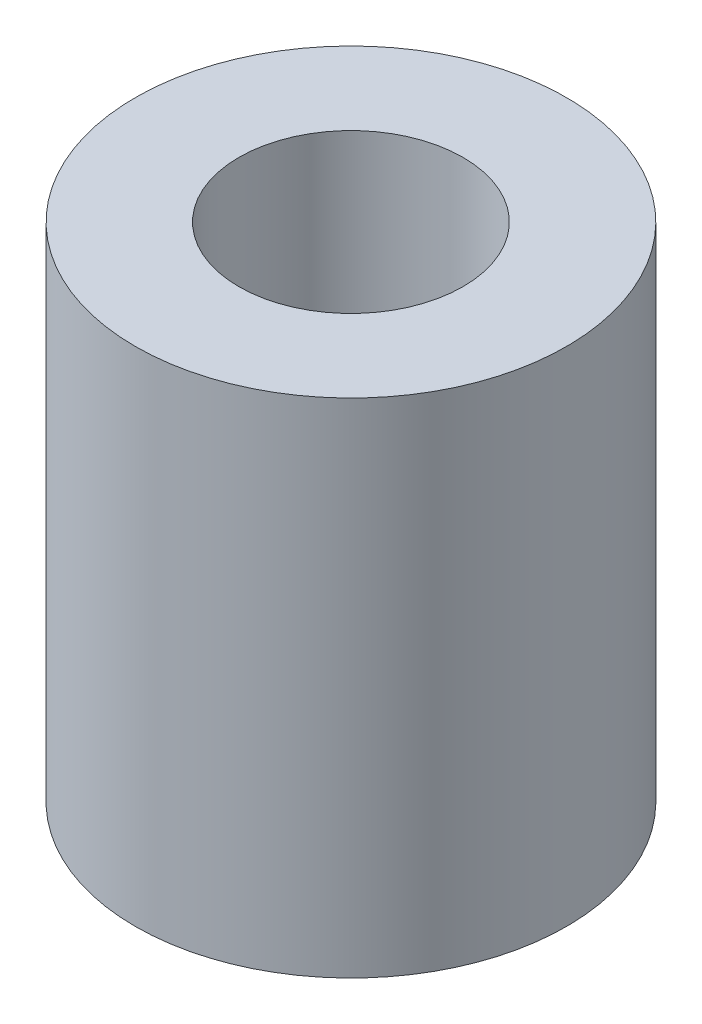
from build123d import *

# Parameters (mm, degrees)
SKETCH1_R           = 6.35
SKETCH1_R_2         = 3.3
BOSS_EXTRUDE1_DEPTH = 14.7955


with BuildPart() as part:
    # Sketch1 → Boss-Extrude1 (new body)
    with BuildSketch(Plane(origin=(0, 0, 0), x_dir=(1, 0, 0), z_dir=(0, 1, 0))):
        Circle(SKETCH1_R)
        Circle(SKETCH1_R_2, mode=Mode.SUBTRACT)
    extrude(amount=BOSS_EXTRUDE1_DEPTH)


solid = part.part
